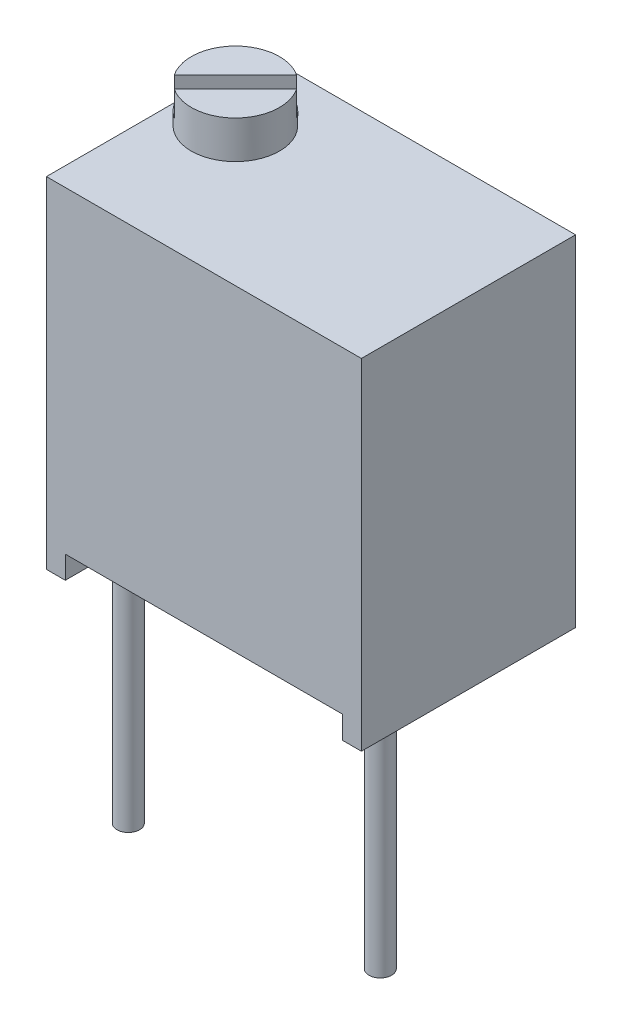
from build123d import *

# Parameters (mm, degrees)
SKETCH3_W               = 6.35
SKETCH3_H               = 6.858
BASE_EXTRUDE_DEPTH      = 1.016
BASE_EXTRUDE_DEPTH_BACK = 3.302
SKETCH4_W               = 5.588
SKETCH4_H               = 0.4572
CUT_EXTRUDE1_DEPTH      = 5.318
SKETCH5_R               = 0.889
BOSS_EXTRUDE1_DEPTH     = 0.762
CUT_EXTRUDE2_DEPTH      = 0.508
SKETCH7_R               = 0.2286
BOSS_EXTRUDE2_DEPTH     = 5.08


with BuildPart() as part:
    # Sketch3 → Base-Extrude (new body, two sides)
    with BuildSketch(Plane.XY) as base_extrude_sk:
        with Locations((2.54, 3.683)):
            Rectangle(SKETCH3_W, SKETCH3_H)
    extrude(amount=BASE_EXTRUDE_DEPTH)
    extrude(base_extrude_sk.sketch, amount=-BASE_EXTRUDE_DEPTH_BACK)

    # Sketch4 → Cut-Extrude1 (cut, through all)
    with BuildSketch(Plane.XY.offset(1.016)):
        with Locations((2.54, 0.4826)):
            Rectangle(SKETCH4_W, SKETCH4_H)
    extrude(amount=-CUT_EXTRUDE1_DEPTH, mode=Mode.SUBTRACT)

    # Sketch5 → Boss-Extrude1 (add)
    with BuildSketch(Plane(origin=(0, 7.112, 0), x_dir=(-1, 0, 0), z_dir=(0, 1, 0))):
        with Locations((-0.381, -1.778)):
            Circle(SKETCH5_R)
    extrude(amount=BOSS_EXTRUDE1_DEPTH)

    # Sketch6 → Cut-Extrude2 (cut)
    with BuildSketch(Plane(origin=(0, 7.874, 0), x_dir=(-1, 0, 0), z_dir=(0, 1, 0))):
        Polygon((-1.153302026, -2.801749198), (0.642749198, -1.005697974), (0.391302026, -0.754250802), (-1.404749198, -2.550302026), align=None)
    extrude(amount=-CUT_EXTRUDE2_DEPTH, mode=Mode.SUBTRACT)

    # Sketch7 → Boss-Extrude2 (add)
    with BuildSketch(Plane.XZ.offset(-0.7112)):
        Circle(SKETCH7_R)
        with Locations((5.08, 0)):
            Circle(SKETCH7_R)
        with Locations((2.54, -2.54)):
            Circle(SKETCH7_R)
    extrude(amount=BOSS_EXTRUDE2_DEPTH)


solid = part.part
